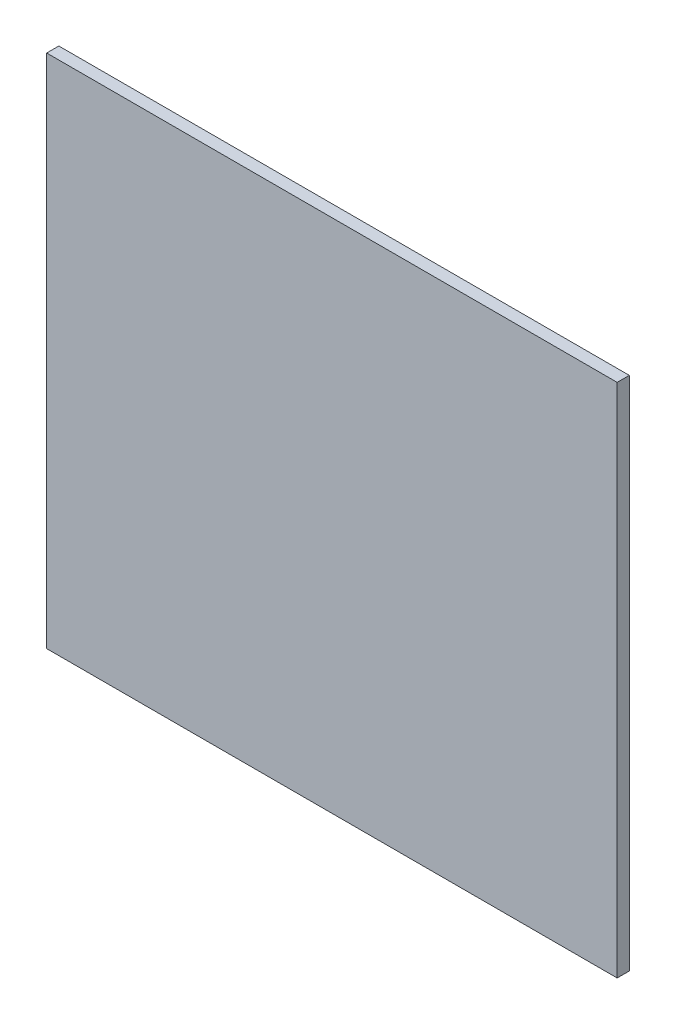
from build123d import *

# Parameters (mm, degrees)
ESQUISSE1_W        = 47
ESQUISSE1_H        = 42.5
BOSS_EXTRU_1_DEPTH = 1


with BuildPart() as part:
    # Esquisse1 → Boss.-Extru.1 (new body)
    with BuildSketch(Plane.XY):
        with Locations((23.5, 21.25)):
            Rectangle(ESQUISSE1_W, ESQUISSE1_H)
    extrude(amount=BOSS_EXTRU_1_DEPTH)


solid = part.part
